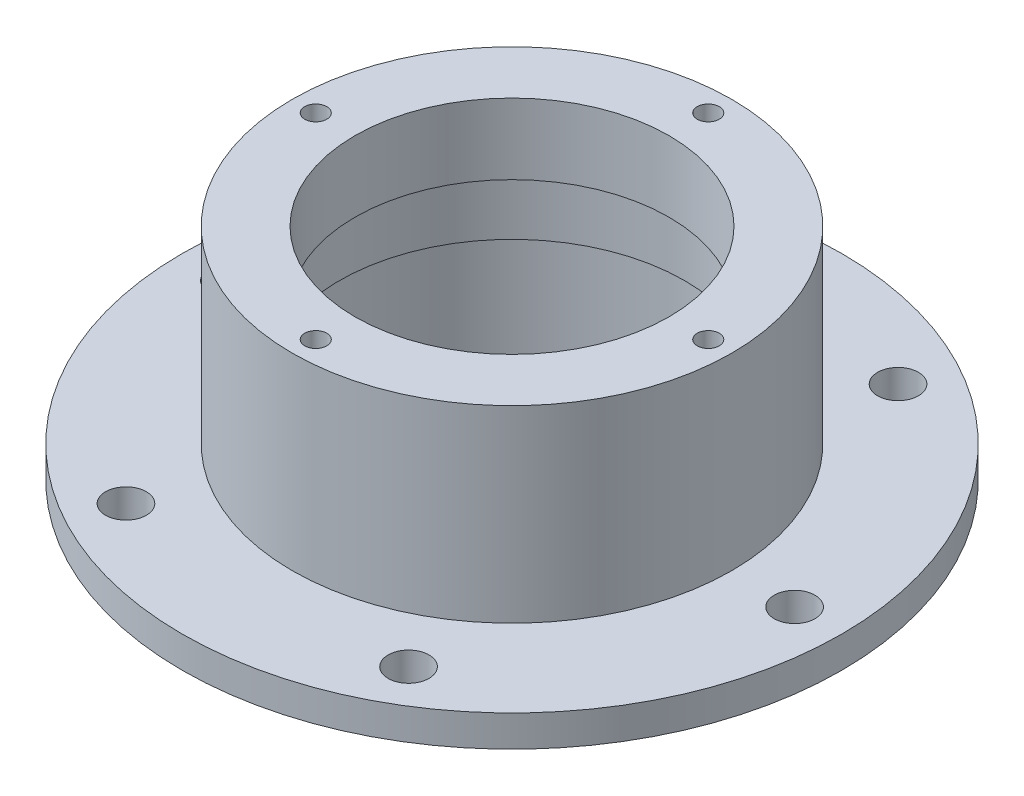
from build123d import *

# Parameters (mm, degrees)
SKETCH1_R              = 105
BOSS_EXTRUDE1_DEPTH    = 75
SKETCH3_R              = 105
SKETCH3_R_2            = 65
CUT_EXTRUDE1_DEPTH     = 5
CUT_EXTRUDE2_REACH     = 92
CUT_EXTRUDE2_START     = -15
SKETCH4_R              = 105
SKETCH4_R_2            = 70
SKETCH5_R              = 55.4
CUT_EXTRUDE3_DEPTH     = 32.5
SKETCH6_R              = 55
CUT_EXTRUDE4_DEPTH     = 20
CUT_EXTRUDE5_REACH     = 24.5
SKETCH7_R              = 50
F_12_0MM_DOWEL_HOLE1_D = 13
F_6_0MM_DOWEL_HOLE1_D  = 7


with BuildPart() as part:
    # Sketch1 → Boss-Extrude1 (new body)
    with BuildSketch(Plane(origin=(0, 0, 0), x_dir=(1, 0, 0), z_dir=(0, 1, 0))):
        Circle(SKETCH1_R)
    extrude(amount=BOSS_EXTRUDE1_DEPTH)

    # Sketch3 → Cut-Extrude1 (cut)
    with BuildSketch(Plane.XZ):
        Circle(SKETCH3_R)
        Circle(SKETCH3_R_2, mode=Mode.SUBTRACT)
    extrude(amount=-CUT_EXTRUDE1_DEPTH, mode=Mode.SUBTRACT)

    # Sketch4 → Cut-Extrude2 (cut, up to next)
    with BuildSketch(Plane.XZ.offset(CUT_EXTRUDE2_START), mode=Mode.PRIVATE) as cut_extrude2_sk1:
        Circle(SKETCH4_R)
        Circle(SKETCH4_R_2, mode=Mode.SUBTRACT)
    cut_extrude2_tool1 = extrude(cut_extrude2_sk1.sketch, amount=-CUT_EXTRUDE2_REACH, mode=Mode.PRIVATE) & part.part
    add(cut_extrude2_tool1.solids().sort_by_distance((-102.030152, 15, 0))[0], mode=Mode.SUBTRACT)

    # Sketch5 → Cut-Extrude3 (cut)
    with BuildSketch(Plane.XZ):
        Circle(SKETCH5_R)
    extrude(amount=-CUT_EXTRUDE3_DEPTH, mode=Mode.SUBTRACT)

    # Sketch6 → Cut-Extrude4 (cut)
    with BuildSketch(Plane.XZ.offset(-32.5)):
        Circle(SKETCH6_R)
    extrude(amount=-CUT_EXTRUDE4_DEPTH, mode=Mode.SUBTRACT)

    # Sketch7 → Cut-Extrude5 (cut, up to next)
    with BuildSketch(Plane.XZ.offset(-52.5), mode=Mode.PRIVATE) as cut_extrude5_sk1:
        Circle(SKETCH7_R)
    cut_extrude5_tool1 = extrude(cut_extrude5_sk1.sketch, amount=-CUT_EXTRUDE5_REACH, mode=Mode.PRIVATE) & part.part
    add(cut_extrude5_tool1.solids().sort_by_distance((0, 52.5, 0))[0], mode=Mode.SUBTRACT)

    # Ø12.0mm Dowel Hole1 (through all)
    with Locations(Plane(origin=(0, 15, 0), x_dir=(1, 0, 0), z_dir=(0, 1, 0))):
        with Locations((45, 77.942286341), (90, 0), (45, -77.942286341), (-45, -77.942286341), (-90, 0), (-45, 77.942286341)):
            Hole(F_12_0MM_DOWEL_HOLE1_D / 2)

    # Ø6.0mm Dowel Hole1 (through all)
    with Locations(Plane(origin=(0, 75, 0), x_dir=(1, 0, 0), z_dir=(0, 1, 0))):
        with Locations((-62.5, 0), (0, 62.5), (62.5, 0), (0, -62.5)):
            Hole(F_6_0MM_DOWEL_HOLE1_D / 2)


solid = part.part
